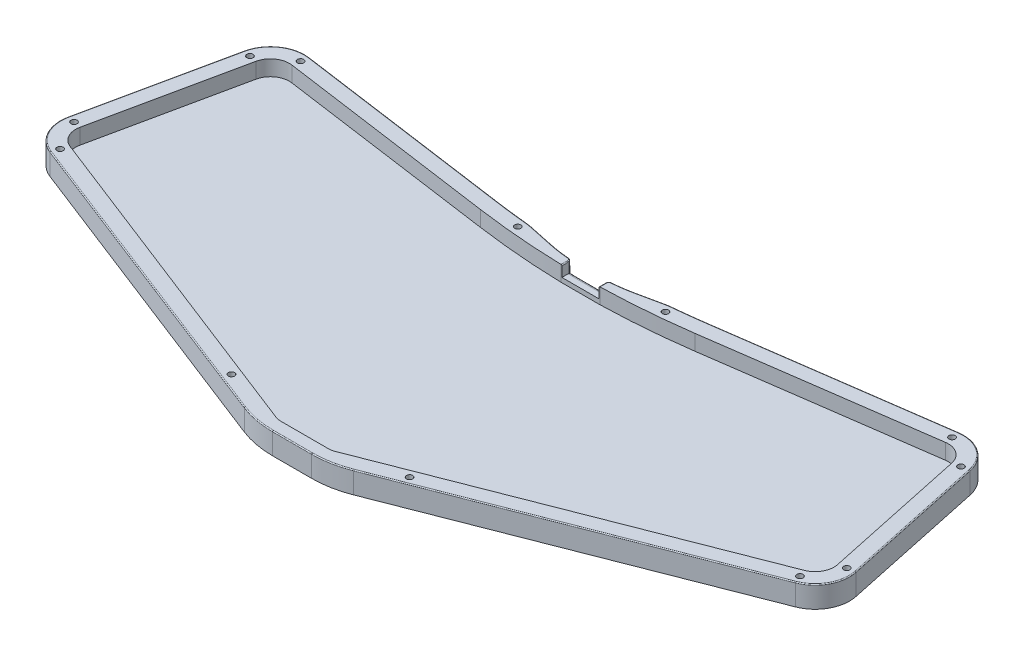
from build123d import *

# Parameters (mm, degrees)
SKETCH1_R           = 1
BOSS_EXTRUDE1_DEPTH = 7
SKETCH1_3_R         = 1
BOSS_EXTRUDE2_DEPTH = 2
CUT_EXTRUDE1_DEPTH  = 9
CUT_EXTRUDE2_DEPTH  = 9
FILLET1_R           = 1
FILLET2_R           = 0.3


with BuildPart() as part:
    # Sketch1 → Boss-Extrude1 (new body)
    with BuildSketch(Plane(origin=(0, 0, 0), x_dir=(1, 0, 0), z_dir=(0, 1, 0))):
        with BuildLine():
            Line((117.612796898, 55.564187288), (111.339376302, 55.564187288))
            ThreePointArc((111.339376302, 55.564187288), (106.112953139, 55.838092519), (100.943791761, 56.656807251))
            Line((100.943791761, 56.656807251), (93.116240963, 58.320604535))
            ThreePointArc((93.116240963, 58.320604535), (92.008917517, 58.523581436), (90.891927529, 58.66393173))
            ThreePointArc((90.891927529, 58.66393173), (85.705266175, 59.223876454), (80.531767276, 59.894624719))
            Line((80.531767276, 59.894624719), (9.710099744, 69.847960989))
            ThreePointArc((9.710099744, 69.847960989), (1.798579876, 67.948573115), (-2.692160046, 61.163805184))
            Line((-2.692160046, 61.163805184), (-12.641867563, 14.354111424))
            ThreePointArc((-12.641867563, 14.354111424), (-11.552749071, 6.774676472), (-5.81501604, 1.703933634))
            Line((-5.81501604, 1.703933634), (96.882509001, -38.318979169))
            ThreePointArc((96.882509001, -38.318979169), (102.430072126, -39.906444336), (108.175414493, -40.4417418))
            Line((108.175414493, -40.4417418), (114.4760866, -40.4417418))
            Line((114.4760866, -40.4417418), (120.776758707, -40.4417418))
            ThreePointArc((120.776758707, -40.4417418), (126.522101074, -39.906444336), (132.069664199, -38.318979169))
            Line((132.069664199, -38.318979169), (234.76718924, 1.703933634))
            ThreePointArc((234.76718924, 1.703933634), (240.504922271, 6.774676472), (241.594040763, 14.354111424))
            Line((241.594040763, 14.354111424), (231.644333246, 61.163805184))
            ThreePointArc((231.644333246, 61.163805184), (227.153593324, 67.948573115), (219.242073456, 69.847960989))
            Line((219.242073456, 69.847960989), (148.420405924, 59.894624719))
            ThreePointArc((148.420405924, 59.894624719), (143.246907025, 59.223876454), (138.060245671, 58.66393173))
            ThreePointArc((138.060245671, 58.66393173), (136.943255683, 58.523581436), (135.835932237, 58.320604535))
            Line((135.835932237, 58.320604535), (128.008381439, 56.656807251))
            ThreePointArc((128.008381439, 56.656807251), (122.839220061, 55.838092519), (117.612796898, 55.564187288))
        make_face()
        with Locations((85.734306388, -31.29120092)):
            Circle(SKETCH1_R, mode=Mode.SUBTRACT)
        with Locations((-4.907226209, 4.033293551)):
            Circle(SKETCH1_R, mode=Mode.SUBTRACT)
        with Locations((-10.19649856, 13.834332199)):
            Circle(SKETCH1_R, mode=Mode.SUBTRACT)
        with BuildLine():
            Line((9.01423424, 64.896620645), (79.835901771, 54.943284375))
            ThreePointArc((79.835901771, 54.943284375), (93.947589546, 53.369014537), (108.1260866, 52.602021276))
            Line((108.1260866, 52.602021276), (120.8260866, 52.602021276))
            ThreePointArc((120.8260866, 52.602021276), (135.004583654, 53.369014537), (149.116271429, 54.943284375))
            Line((149.116271429, 54.943284375), (219.93793896, 64.896620645))
            ThreePointArc((219.93793896, 64.896620645), (224.28571114, 63.852812894), (226.753595242, 60.124246735))
            Line((226.753595242, 60.124246735), (236.703302758, 13.314552975))
            ThreePointArc((236.703302758, 13.314552975), (236.104778182, 9.149277911), (232.951609579, 6.362653468))
            Line((232.951609579, 6.362653468), (130.254084538, -33.660259335))
            Line((130.254084538, -33.660259335), (123.992602822, -36.100461634))
            ThreePointArc((123.992602822, -36.100461634), (123.100711644, -36.355681114), (122.177023161, -36.4417418))
            Line((122.177023161, -36.4417418), (120.9760866, -36.4417418))
            Line((120.9760866, -36.4417418), (119.4760866, -36.4417418))
            Line((119.4760866, -36.4417418), (114.4760866, -36.4417418))
            Line((114.4760866, -36.4417418), (109.4760866, -36.4417418))
            Line((109.4760866, -36.4417418), (107.9760866, -36.4417418))
            Line((107.9760866, -36.4417418), (106.775150039, -36.4417418))
            ThreePointArc((106.775150039, -36.4417418), (105.851461556, -36.355681114), (104.959570378, -36.100461634))
            Line((104.959570378, -36.100461634), (98.698088662, -33.660259335))
            Line((98.698088662, -33.660259335), (-3.999436379, 6.362653468))
            ThreePointArc((-3.999436379, 6.362653468), (-7.152604982, 9.149277911), (-7.751129558, 13.314552975))
            Line((-7.751129558, 13.314552975), (2.198577958, 60.124246735))
            ThreePointArc((2.198577958, 60.124246735), (4.66646206, 63.852812894), (9.01423424, 64.896620645))
        make_face(mode=Mode.SUBTRACT)
        with Locations((143.217866812, -31.29120092)):
            Circle(SKETCH1_R, mode=Mode.SUBTRACT)
        with Locations((233.859399409, 4.033293551)):
            Circle(SKETCH1_R, mode=Mode.SUBTRACT)
        with Locations((239.14867176, 13.834332199)):
            Circle(SKETCH1_R, mode=Mode.SUBTRACT)
        with Locations((-0.246791044, 60.64402596)):
            Circle(SKETCH1_R, mode=Mode.SUBTRACT)
        with Locations((9.362166992, 67.372290817)):
            Circle(SKETCH1_R, mode=Mode.SUBTRACT)
        with Locations((90.650187482, 56.175646828)):
            Circle(SKETCH1_R, mode=Mode.SUBTRACT)
        with Locations((138.301985718, 56.175646828)):
            Circle(SKETCH1_R, mode=Mode.SUBTRACT)
        with Locations((229.198964244, 60.64402596)):
            Circle(SKETCH1_R, mode=Mode.SUBTRACT)
        with Locations((219.590006208, 67.372290817)):
            Circle(SKETCH1_R, mode=Mode.SUBTRACT)
    extrude(amount=BOSS_EXTRUDE1_DEPTH)

    # Sketch1_3 → Boss-Extrude2 (add)
    with BuildSketch(Plane(origin=(0, 0, 0), x_dir=(1, 0, 0), z_dir=(0, 1, 0))):
        with BuildLine():
            ThreePointArc((108.1260866, 52.602021276), (93.947589546, 53.369014537), (79.835901771, 54.943284375))
            Line((79.835901771, 54.943284375), (9.01423424, 64.896620645))
            ThreePointArc((9.01423424, 64.896620645), (4.66646206, 63.852812894), (2.198577958, 60.124246735))
            Line((2.198577958, 60.124246735), (-7.751129558, 13.314552975))
            ThreePointArc((-7.751129558, 13.314552975), (-7.152604982, 9.149277911), (-3.999436379, 6.362653468))
            Line((-3.999436379, 6.362653468), (104.959570378, -36.100461634))
            ThreePointArc((104.959570378, -36.100461634), (105.851461556, -36.355681114), (106.775150039, -36.4417418))
            Line((106.775150039, -36.4417418), (122.177023161, -36.4417418))
            ThreePointArc((122.177023161, -36.4417418), (123.100711644, -36.355681114), (123.992602822, -36.100461634))
            Line((123.992602822, -36.100461634), (232.951609579, 6.362653468))
            ThreePointArc((232.951609579, 6.362653468), (236.104778182, 9.149277911), (236.703302758, 13.314552975))
            Line((236.703302758, 13.314552975), (226.753595242, 60.124246735))
            ThreePointArc((226.753595242, 60.124246735), (224.28571114, 63.852812894), (219.93793896, 64.896620645))
            Line((219.93793896, 64.896620645), (149.116271429, 54.943284375))
            ThreePointArc((149.116271429, 54.943284375), (135.004583654, 53.369014537), (120.8260866, 52.602021276))
            Line((120.8260866, 52.602021276), (108.1260866, 52.602021276))
        make_face()
        with Locations((-10.19649856, 13.834332199)):
            Circle(SKETCH1_3_R)
        with Locations((239.14867176, 13.834332199)):
            Circle(SKETCH1_3_R)
        with Locations((-0.246791044, 60.64402596)):
            Circle(SKETCH1_3_R)
        with Locations((229.198964244, 60.64402596)):
            Circle(SKETCH1_3_R)
        with Locations((143.217866812, -31.29120092)):
            Circle(SKETCH1_3_R)
        with Locations((85.734306388, -31.29120092)):
            Circle(SKETCH1_3_R)
        with Locations((9.362166992, 67.372290817)):
            Circle(SKETCH1_3_R)
        with Locations((90.650187482, 56.175646828)):
            Circle(SKETCH1_3_R)
        with Locations((138.301985718, 56.175646828)):
            Circle(SKETCH1_3_R)
        with Locations((219.590006208, 67.372290817)):
            Circle(SKETCH1_3_R)
        with Locations((-4.907226209, 4.033293551)):
            Circle(SKETCH1_3_R)
        with Locations((233.859399409, 4.033293551)):
            Circle(SKETCH1_3_R)
    extrude(amount=BOSS_EXTRUDE2_DEPTH)

    # Sketch2 → Cut-Extrude1 (cut)
    with BuildSketch(Plane(origin=(0, 0, -55.564187288), x_dir=(-1, 0, 0), z_dir=(0, 0, -1))):
        Polygon((-114.4760866, 7), (-120.4760866, 7), (-120.4760866, 3.5), (-114.4760866, 3.5), (-108.4760866, 3.5), (-108.4760866, 7), align=None)
    extrude(amount=-CUT_EXTRUDE1_DEPTH, mode=Mode.SUBTRACT)

    # Sketch2_2 → Cut-Extrude2 (cut)
    with BuildSketch(Plane(origin=(0, 0, -55.564187288), x_dir=(-1, 0, 0), z_dir=(0, 0, -1))):
        Polygon((-114.4760866, 7), (-120.4760866, 7), (-120.4760866, 3.5), (-114.4760866, 3.5), (-108.4760866, 3.5), (-108.4760866, 7), align=None)
    extrude(amount=CUT_EXTRUDE2_DEPTH, mode=Mode.SUBTRACT)

    # Fillet1
    fillet1_edges = [part.edges().sort_by_distance(p)[0] for p in [
        (109.907143745, 3.5, -55.584704398),
        (114.4760866, 3.5, -55.564187288),
        (108.4760866, 5.25, -55.646238892),
        (119.045029455, 3.5, -55.584704398),
        (120.4760866, 5.25, -55.646238892),
    ]]
    fillet(fillet1_edges, radius=FILLET1_R)

    # Fillet2
    fillet2_edges = [part.edges().sort_by_distance(p)[0] for p in [
        (108.4760866, 7, -53.656371339),
        (120.4760866, 7, -53.656371339),
        (108.209486484, 7, -55.390518879),
        (120.742686716, 7, -55.390518879),
        (104.231959146, 7, -56.071918989),
        (124.720214054, 7, -56.071918989),
        (97.030016362, 7, -57.488705893),
        (131.922156838, 7, -57.488705893),
        (92.008917517, 7, -58.523581436),
        (136.943255683, 7, -58.523581436),
        (85.705266175, 7, -59.223876454),
        (143.246907025, 7, -59.223876454),
        (45.12093351, 7, -64.871292854),
        (183.83123969, 7, -64.871292854),
        (1.798579876, 7, -67.948573115),
        (227.153593324, 7, -67.948573115),
        (-7.667013804, 7, -37.758958304),
        (236.619187004, 7, -37.758958304),
        (-11.552749071, 7, -6.774676472),
        (240.504922271, 7, -6.774676472),
        (45.533746481, 7, 18.307522768),
        (183.418426719, 7, 18.307522768),
        (102.430072126, 7, 39.906444336),
        (126.522101074, 7, 39.906444336),
        (114.4760866, 7, 40.4417418),
    ]]
    fillet(fillet2_edges, radius=FILLET2_R)


solid = part.part
